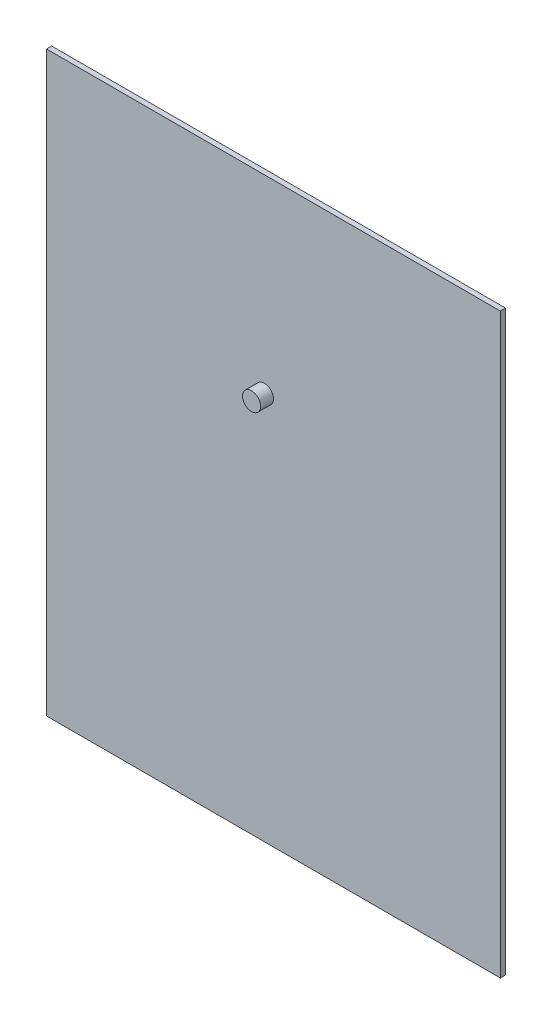
from build123d import *

# Parameters (mm, degrees)
SKETCH_1_W      = 176
SKETCH_1_H      = 224
EXTRUDE_1_DEPTH = 2
SKETCH_2_R      = 3.5
EXTRUDE_2_DEPTH = 5


with BuildPart() as part:
    # 草图1 → 凸台-拉伸1 (new body)
    with BuildSketch(Plane.XY):
        with Locations((42.151287843, -76.562598062)):
            Rectangle(SKETCH_1_W, SKETCH_1_H)
    extrude(amount=EXTRUDE_1_DEPTH)

    # 草图2 → 凸台-拉伸2 (add)
    with BuildSketch(Plane.XY.offset(2)):
        with Locations((38.665338102, -38.071903006)):
            Circle(SKETCH_2_R)
    extrude(amount=EXTRUDE_2_DEPTH)


solid = part.part
